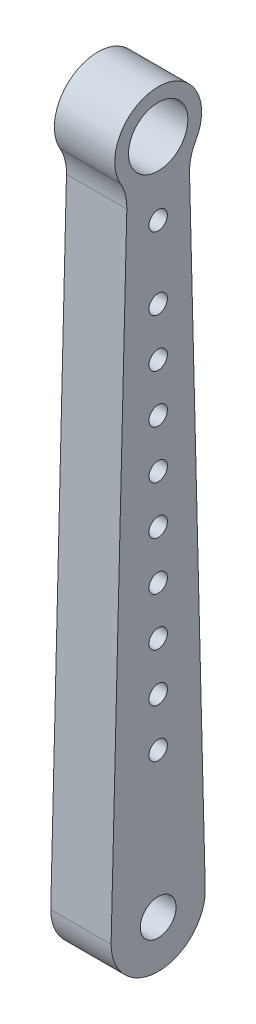
from build123d import *

# Parameters (mm, degrees)
VERTICAL_BAR_DEPTH     = 15.875
CUT_CABLE_HOLDER_REACH = 17.875
SKETCH5_R              = 2.413
CUT_PIVOT_HOLE_REACH   = 17.875
SKETCH6_R              = 4.7117
CUT_EXTRUDE8_DEPTH     = 16.875
SLOT_CUT_DEPTH         = 7.62
SKETCH10_R             = 7.8105
CUT_EXTRUDE9_DEPTH     = 16.875
FILLET1_R              = 12.7


with BuildPart() as part:
    # Sketch3 → Vertical Bar (new body)
    with BuildSketch(Plane(origin=(0, 0, 0), x_dir=(0, 0, -1), z_dir=(1, 0, 0))):
        with BuildLine():
            Line((-12.7, -12.7), (12.7, -12.7))
            Line((12.7, -12.7), (8.138209265, 169.714598123))
            ThreePointArc((8.138209265, 169.714598123), (0, 189.170459445), (-8.138209265, 169.714598123))
            Line((-8.138209265, 169.714598123), (-12.7, -12.7))
        make_face()
    extrude(amount=-VERTICAL_BAR_DEPTH)

    # Sketch5 → Cut-Cable holder (cut, up to next)
    with BuildSketch(Plane(origin=(0, 0, 0), x_dir=(0, 0, -1), z_dir=(1, 0, 0)), mode=Mode.PRIVATE) as cut_cable_holder_sk1:
        with Locations((0, 50.8)):
            Circle(SKETCH5_R)
    cut_cable_holder_tool1 = extrude(cut_cable_holder_sk1.sketch, amount=-CUT_CABLE_HOLDER_REACH, mode=Mode.PRIVATE) & part.part
    add(cut_cable_holder_tool1.solids().sort_by_distance((0, 50.8, 0))[0], mode=Mode.SUBTRACT)
    # Sketch5 → Cut-Cable holder (cut, up to next)
    with BuildSketch(Plane(origin=(0, 0, 0), x_dir=(0, 0, -1), z_dir=(1, 0, 0)), mode=Mode.PRIVATE) as cut_cable_holder_sk2:
        with Locations((0, 63.5)):
            Circle(SKETCH5_R)
    cut_cable_holder_tool2 = extrude(cut_cable_holder_sk2.sketch, amount=-CUT_CABLE_HOLDER_REACH, mode=Mode.PRIVATE) & part.part
    add(cut_cable_holder_tool2.solids().sort_by_distance((0, 63.5, 0))[0], mode=Mode.SUBTRACT)
    # Sketch5 → Cut-Cable holder (cut, up to next)
    with BuildSketch(Plane(origin=(0, 0, 0), x_dir=(0, 0, -1), z_dir=(1, 0, 0)), mode=Mode.PRIVATE) as cut_cable_holder_sk3:
        with Locations((0, 76.2)):
            Circle(SKETCH5_R)
    cut_cable_holder_tool3 = extrude(cut_cable_holder_sk3.sketch, amount=-CUT_CABLE_HOLDER_REACH, mode=Mode.PRIVATE) & part.part
    add(cut_cable_holder_tool3.solids().sort_by_distance((0, 76.2, 0))[0], mode=Mode.SUBTRACT)
    # Sketch5 → Cut-Cable holder (cut, up to next)
    with BuildSketch(Plane(origin=(0, 0, 0), x_dir=(0, 0, -1), z_dir=(1, 0, 0)), mode=Mode.PRIVATE) as cut_cable_holder_sk4:
        with Locations((0, 88.9)):
            Circle(SKETCH5_R)
    cut_cable_holder_tool4 = extrude(cut_cable_holder_sk4.sketch, amount=-CUT_CABLE_HOLDER_REACH, mode=Mode.PRIVATE) & part.part
    add(cut_cable_holder_tool4.solids().sort_by_distance((0, 88.9, 0))[0], mode=Mode.SUBTRACT)
    # Sketch5 → Cut-Cable holder (cut, up to next)
    with BuildSketch(Plane(origin=(0, 0, 0), x_dir=(0, 0, -1), z_dir=(1, 0, 0)), mode=Mode.PRIVATE) as cut_cable_holder_sk5:
        with Locations((0, 101.6)):
            Circle(SKETCH5_R)
    cut_cable_holder_tool5 = extrude(cut_cable_holder_sk5.sketch, amount=-CUT_CABLE_HOLDER_REACH, mode=Mode.PRIVATE) & part.part
    add(cut_cable_holder_tool5.solids().sort_by_distance((0, 101.6, 0))[0], mode=Mode.SUBTRACT)
    # Sketch5 → Cut-Cable holder (cut, up to next)
    with BuildSketch(Plane(origin=(0, 0, 0), x_dir=(0, 0, -1), z_dir=(1, 0, 0)), mode=Mode.PRIVATE) as cut_cable_holder_sk6:
        with Locations((0, 114.3)):
            Circle(SKETCH5_R)
    cut_cable_holder_tool6 = extrude(cut_cable_holder_sk6.sketch, amount=-CUT_CABLE_HOLDER_REACH, mode=Mode.PRIVATE) & part.part
    add(cut_cable_holder_tool6.solids().sort_by_distance((0, 114.3, 0))[0], mode=Mode.SUBTRACT)
    # Sketch5 → Cut-Cable holder (cut, up to next)
    with BuildSketch(Plane(origin=(0, 0, 0), x_dir=(0, 0, -1), z_dir=(1, 0, 0)), mode=Mode.PRIVATE) as cut_cable_holder_sk7:
        with Locations((0, 127)):
            Circle(SKETCH5_R)
    cut_cable_holder_tool7 = extrude(cut_cable_holder_sk7.sketch, amount=-CUT_CABLE_HOLDER_REACH, mode=Mode.PRIVATE) & part.part
    add(cut_cable_holder_tool7.solids().sort_by_distance((0, 127, 0))[0], mode=Mode.SUBTRACT)
    # Sketch5 → Cut-Cable holder (cut, up to next)
    with BuildSketch(Plane(origin=(0, 0, 0), x_dir=(0, 0, -1), z_dir=(1, 0, 0)), mode=Mode.PRIVATE) as cut_cable_holder_sk8:
        with Locations((0, 139.7)):
            Circle(SKETCH5_R)
    cut_cable_holder_tool8 = extrude(cut_cable_holder_sk8.sketch, amount=-CUT_CABLE_HOLDER_REACH, mode=Mode.PRIVATE) & part.part
    add(cut_cable_holder_tool8.solids().sort_by_distance((0, 139.7, 0))[0], mode=Mode.SUBTRACT)
    # Sketch5 → Cut-Cable holder (cut, up to next)
    with BuildSketch(Plane(origin=(0, 0, 0), x_dir=(0, 0, -1), z_dir=(1, 0, 0)), mode=Mode.PRIVATE) as cut_cable_holder_sk9:
        with Locations((0, 158.75)):
            Circle(SKETCH5_R)
    cut_cable_holder_tool9 = extrude(cut_cable_holder_sk9.sketch, amount=-CUT_CABLE_HOLDER_REACH, mode=Mode.PRIVATE) & part.part
    add(cut_cable_holder_tool9.solids().sort_by_distance((0, 158.75, 0))[0], mode=Mode.SUBTRACT)
    # Sketch5 → Cut-Cable holder (cut, up to next)
    with BuildSketch(Plane(origin=(0, 0, 0), x_dir=(0, 0, -1), z_dir=(1, 0, 0)), mode=Mode.PRIVATE) as cut_cable_holder_sk10:
        with Locations((0, 38.1)):
            Circle(SKETCH5_R)
    cut_cable_holder_tool10 = extrude(cut_cable_holder_sk10.sketch, amount=-CUT_CABLE_HOLDER_REACH, mode=Mode.PRIVATE) & part.part
    add(cut_cable_holder_tool10.solids().sort_by_distance((0, 38.1, 0))[0], mode=Mode.SUBTRACT)

    # Sketch6 → Cut-Pivot hole (cut, up to next)
    with BuildSketch(Plane(origin=(0, 0, 0), x_dir=(0, 0, -1), z_dir=(1, 0, 0)), mode=Mode.PRIVATE) as cut_pivot_hole_sk1:
        Circle(SKETCH6_R)
    cut_pivot_hole_tool1 = extrude(cut_pivot_hole_sk1.sketch, amount=-CUT_PIVOT_HOLE_REACH, mode=Mode.PRIVATE) & part.part
    add(cut_pivot_hole_tool1.solids().sort_by_distance((0, 0, 0))[0], mode=Mode.SUBTRACT)

    # Sketch8 → Cut-Extrude8 (cut, through all)
    with BuildSketch(Plane(origin=(0, 0, 0), x_dir=(0, 0, -1), z_dir=(1, 0, 0))):
        with BuildLine():
            Line((-12.382400735, 0), (-12.7, -12.7))
            Line((-12.7, -12.7), (12.7, -12.7))
            Line((12.7, -12.7), (12.382400735, 0))
            ThreePointArc((12.382400735, 0), (0, -12.382400735), (-12.382400735, 0))
        make_face()
    extrude(amount=-CUT_EXTRUDE8_DEPTH, mode=Mode.SUBTRACT)

    # Sketch9 → Slot Cut (cut)
    with BuildSketch(Plane.ZY.offset(15.875)):
        with BuildLine():
            Line((-6.35, 140.97), (-6.35, 31.75))
            ThreePointArc((-6.35, 31.75), (0, 25.4), (6.35, 31.75))
            Line((6.35, 31.75), (6.35, 140.97))
            ThreePointArc((6.35, 140.97), (0, 147.32), (-6.35, 140.97))
        make_face()
    extrude(amount=-SLOT_CUT_DEPTH, mode=Mode.SUBTRACT)

    # Sketch10 → Cut-Extrude9 (cut, through all)
    with BuildSketch(Plane(origin=(0, 0, 0), x_dir=(0, 0, -1), z_dir=(1, 0, 0))):
        with Locations((0, 177.8)):
            Circle(SKETCH10_R)
    extrude(amount=-CUT_EXTRUDE9_DEPTH, mode=Mode.SUBTRACT)

    # Fillet1
    fillet1_edges = [part.edges().sort_by_distance(p)[0] for p in [
        (-7.9375, 169.714598123, 8.138209265),
        (-7.9375, 169.714598123, -8.138209265),
    ]]
    fillet(fillet1_edges, radius=FILLET1_R)


solid = part.part
